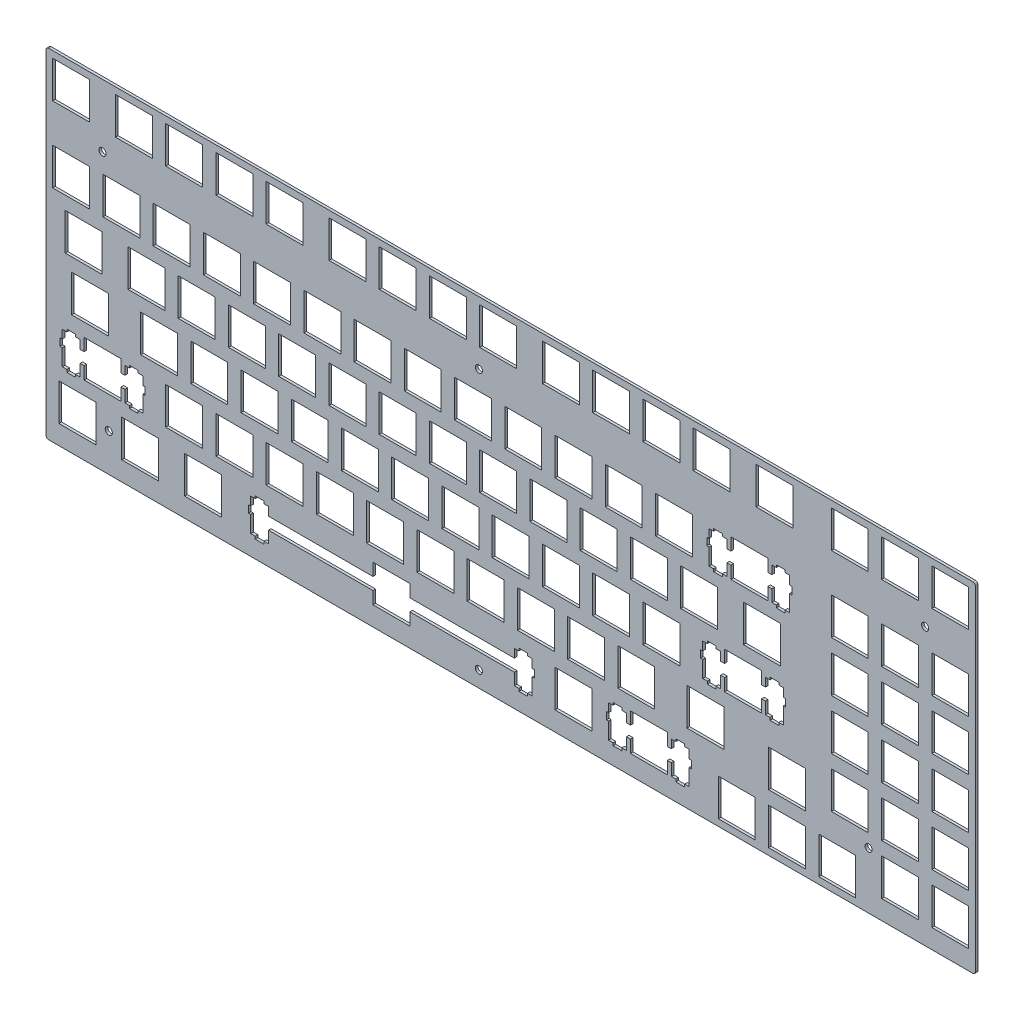
from build123d import *

# Parameters (mm, degrees)
MODEL_W             = 352.4249154
MODEL_H             = 128.586918
MODEL_W_2           = 14
MODEL_H_2           = 13.99947
MODEL_W_3           = 13.99949
MODEL_H_3           = 13.99948
MODEL_W_4           = 14.0008
MODEL_W_5           = 13.9993
MODEL_W_6           = 13.999
MODEL_H_4           = 13.9994
MODEL_W_7           = 14.00087
MODEL_H_5           = 13.9992
MODEL_W_8           = 13.9998
MODEL_W_9           = 13.99954
MODEL_W_10          = 13.99955
MODEL_W_11          = 14.0007
MODEL_W_12          = 14.001
MODEL_H_6           = 13.999
EXTRUDE_1_DEPTH     = 1
FILLET_1_R          = 1
SKETCH_2_R          = 1.35
CUT_EXTRUDE_1_DEPTH = 1.5


with BuildPart() as part:
    # Model → 凸台-拉伸1 (new body)
    with BuildSketch(Plane.XY):
        with Locations((176.3075423, 64.727541)):
            Rectangle(MODEL_W, MODEL_H)
        with Locations((262.032, 9.959765)):
            Rectangle(MODEL_W_2, MODEL_H_2, mode=Mode.SUBTRACT)
        with Locations((281.082, 9.959765)):
            Rectangle(MODEL_W_2, MODEL_H_2, mode=Mode.SUBTRACT)
        with Locations((300.132, 9.959765)):
            Rectangle(MODEL_W_2, MODEL_H_2, mode=Mode.SUBTRACT)
        Polygon((124.062, 21.722), (124.062, 17.0215), (84.4381, 17.0215), (84.4381, 20.2517), (82.7126, 20.2517), (82.7126, 21.1722), (79.412, 21.1722), (79.412, 20.2517), (77.687, 20.2517), (77.687, 17.0215), (76.8629, 17.0215), (76.8629, 14.2227), (77.687, 14.2227), (77.687, 7.95267), (79.412, 7.95267), (79.412, 6.97149), (82.7126, 6.97149), (82.7126, 7.95267), (84.4381, 7.95267), (84.4381, 12.4216), (124.062, 12.4216), (124.062, 7.72252), (138.063, 7.72252), (138.063, 12.4216), (177.687, 12.4216), (177.687, 7.95267), (179.412, 7.95267), (179.412, 6.97149), (182.713, 6.97149), (182.713, 7.95267), (184.438, 7.95267), (184.438, 14.2227), (185.262, 14.2227), (185.262, 17.0215), (184.438, 17.0215), (184.438, 20.2517), (182.713, 20.2517), (182.713, 21.1722), (179.412, 21.1722), (179.412, 20.2517), (177.687, 20.2517), (177.687, 17.0215), (138.063, 17.0215), (138.063, 21.722), align=None, mode=Mode.SUBTRACT)
        Polygon((221.695, 21.722), (221.695, 17.0215), (220.169, 17.0215), (220.169, 20.2517), (218.444, 20.2517), (218.444, 21.1722), (215.145, 21.1722), (215.145, 20.2517), (213.42, 20.2517), (213.42, 17.0215), (212.594, 17.0215), (212.594, 14.2227), (213.42, 14.2227), (213.42, 7.95267), (215.145, 7.95267), (215.145, 6.97149), (218.444, 6.97149), (218.444, 7.95267), (220.169, 7.95267), (220.169, 12.4216), (221.695, 12.4216), (221.695, 7.72252), (235.694, 7.72252), (235.694, 12.4216), (237.22, 12.4216), (237.22, 7.95267), (238.945, 7.95267), (238.945, 6.97149), (242.244, 6.97149), (242.244, 7.95267), (243.969, 7.95267), (243.969, 14.2227), (244.795, 14.2227), (244.795, 17.0215), (243.969, 17.0215), (243.969, 20.2517), (242.244, 20.2517), (242.244, 21.1722), (238.945, 21.1722), (238.945, 20.2517), (237.22, 20.2517), (237.22, 17.0215), (235.694, 17.0215), (235.694, 21.722), align=None, mode=Mode.SUBTRACT)
        with Locations((12.000655, 14.72226)):
            Rectangle(MODEL_W_3, MODEL_H_3, mode=Mode.SUBTRACT)
        with Locations((35.8124, 14.72226)):
            Rectangle(MODEL_W_4, MODEL_H_3, mode=Mode.SUBTRACT)
        with Locations((59.62565, 14.72226)):
            Rectangle(MODEL_W_5, MODEL_H_3, mode=Mode.SUBTRACT)
        with Locations((200.1195, 14.72226)):
            Rectangle(MODEL_W_6, MODEL_H_3, mode=Mode.SUBTRACT)
        with Locations((323.9445, 14.72226)):
            Rectangle(MODEL_W_6, MODEL_H_3, mode=Mode.SUBTRACT)
        with Locations((342.9945, 14.72226)):
            Rectangle(MODEL_W_6, MODEL_H_3, mode=Mode.SUBTRACT)
        with Locations((281.082, 29.0097)):
            Rectangle(MODEL_W_2, MODEL_H_4, mode=Mode.SUBTRACT)
        Polygon((14.5259, 40.7719), (14.5259, 36.0715), (13.0004, 36.0715), (13.0004, 39.3016), (11.2751, 39.3016), (11.2751, 40.2223), (7.97609, 40.2223), (7.97609, 39.3016), (6.2508, 39.3016), (6.2508, 36.0715), (5.42533, 36.0715), (5.42533, 33.2727), (6.2508, 33.2727), (6.2508, 27.0027), (7.97609, 27.0027), (7.97609, 26.0215), (11.2751, 26.0215), (11.2751, 27.0027), (13.0004, 27.0027), (13.0004, 31.4716), (14.5259, 31.4716), (14.5259, 26.7725), (28.5254, 26.7725), (28.5254, 31.4716), (30.0509, 31.4716), (30.0509, 27.0027), (31.7748, 27.0027), (31.7748, 26.0215), (35.0752, 26.0215), (35.0752, 27.0027), (36.8004, 27.0027), (36.8004, 33.2727), (37.6259, 33.2727), (37.6259, 36.0715), (36.8004, 36.0715), (36.8004, 39.3016), (35.0752, 39.3016), (35.0752, 40.2223), (31.7748, 40.2223), (31.7748, 39.3016), (30.0509, 39.3016), (30.0509, 36.0715), (28.5254, 36.0715), (28.5254, 40.7719), align=None, mode=Mode.SUBTRACT)
        with Locations((52.48185, 33.7722)):
            Rectangle(MODEL_W_5, MODEL_H_4, mode=Mode.SUBTRACT)
        with Locations((71.53185, 33.7722)):
            Rectangle(MODEL_W_5, MODEL_H_4, mode=Mode.SUBTRACT)
        with Locations((90.58185, 33.7722)):
            Rectangle(MODEL_W_5, MODEL_H_4, mode=Mode.SUBTRACT)
        with Locations((109.632, 33.7722)):
            Rectangle(MODEL_W_2, MODEL_H_4, mode=Mode.SUBTRACT)
        with Locations((128.682, 33.7722)):
            Rectangle(MODEL_W_2, MODEL_H_4, mode=Mode.SUBTRACT)
        with Locations((147.732, 33.7722)):
            Rectangle(MODEL_W_2, MODEL_H_4, mode=Mode.SUBTRACT)
        with Locations((166.782, 33.7722)):
            Rectangle(MODEL_W_2, MODEL_H_4, mode=Mode.SUBTRACT)
        with Locations((185.832, 33.7722)):
            Rectangle(MODEL_W_2, MODEL_H_4, mode=Mode.SUBTRACT)
        with Locations((204.882, 33.7722)):
            Rectangle(MODEL_W_2, MODEL_H_4, mode=Mode.SUBTRACT)
        with Locations((223.932, 33.7722)):
            Rectangle(MODEL_W_2, MODEL_H_4, mode=Mode.SUBTRACT)
        with Locations((250.1255, 33.7722)):
            Rectangle(MODEL_W_6, MODEL_H_4, mode=Mode.SUBTRACT)
        with Locations((304.8945, 33.7722)):
            Rectangle(MODEL_W_6, MODEL_H_4, mode=Mode.SUBTRACT)
        with Locations((323.9445, 33.7722)):
            Rectangle(MODEL_W_6, MODEL_H_4, mode=Mode.SUBTRACT)
        with Locations((342.9945, 33.7722)):
            Rectangle(MODEL_W_6, MODEL_H_4, mode=Mode.SUBTRACT)
        Polygon((257.412, 59.8219), (257.412, 55.1215), (255.888, 55.1215), (255.888, 58.3516), (254.161, 58.3516), (254.161, 59.2723), (250.862, 59.2723), (250.862, 58.3516), (249.137, 58.3516), (249.137, 55.1215), (248.313, 55.1215), (248.313, 52.3226), (249.137, 52.3226), (249.137, 46.0527), (250.862, 46.0527), (250.862, 45.0716), (254.161, 45.0716), (254.161, 46.0527), (255.888, 46.0527), (255.888, 50.5217), (257.412, 50.5217), (257.412, 45.8227), (271.413, 45.8227), (271.413, 50.5217), (272.937, 50.5217), (272.937, 46.0527), (274.662, 46.0527), (274.662, 45.0716), (277.963, 45.0716), (277.963, 46.0527), (279.688, 46.0527), (279.688, 52.3226), (280.512, 52.3226), (280.512, 55.1215), (279.688, 55.1215), (279.688, 58.3516), (277.963, 58.3516), (277.963, 59.2723), (274.662, 59.2723), (274.662, 58.3516), (272.937, 58.3516), (272.937, 55.1215), (271.413, 55.1215), (271.413, 59.8219), align=None, mode=Mode.SUBTRACT)
        with Locations((16.762465, 52.8223)):
            Rectangle(MODEL_W_7, MODEL_H_5, mode=Mode.SUBTRACT)
        with Locations((42.95685, 52.8223)):
            Rectangle(MODEL_W_5, MODEL_H_5, mode=Mode.SUBTRACT)
        with Locations((62.00685, 52.8223)):
            Rectangle(MODEL_W_5, MODEL_H_5, mode=Mode.SUBTRACT)
        with Locations((81.05685, 52.8223)):
            Rectangle(MODEL_W_5, MODEL_H_5, mode=Mode.SUBTRACT)
        with Locations((100.1071, 52.8223)):
            Rectangle(MODEL_W_8, MODEL_H_5, mode=Mode.SUBTRACT)
        with Locations((119.157, 52.8223)):
            Rectangle(MODEL_W_2, MODEL_H_5, mode=Mode.SUBTRACT)
        with Locations((138.207, 52.8223)):
            Rectangle(MODEL_W_2, MODEL_H_5, mode=Mode.SUBTRACT)
        with Locations((157.257, 52.8223)):
            Rectangle(MODEL_W_2, MODEL_H_5, mode=Mode.SUBTRACT)
        with Locations((176.307, 52.8223)):
            Rectangle(MODEL_W_2, MODEL_H_5, mode=Mode.SUBTRACT)
        with Locations((195.357, 52.8223)):
            Rectangle(MODEL_W_2, MODEL_H_5, mode=Mode.SUBTRACT)
        with Locations((214.407, 52.8223)):
            Rectangle(MODEL_W_2, MODEL_H_5, mode=Mode.SUBTRACT)
        with Locations((233.457, 52.8223)):
            Rectangle(MODEL_W_2, MODEL_H_5, mode=Mode.SUBTRACT)
        with Locations((304.8945, 52.8223)):
            Rectangle(MODEL_W_6, MODEL_H_5, mode=Mode.SUBTRACT)
        with Locations((323.9445, 52.8223)):
            Rectangle(MODEL_W_6, MODEL_H_5, mode=Mode.SUBTRACT)
        with Locations((342.9945, 52.8223)):
            Rectangle(MODEL_W_6, MODEL_H_5, mode=Mode.SUBTRACT)
        with Locations((14.38193, 71.8723)):
            Rectangle(MODEL_W_9, MODEL_H_5, mode=Mode.SUBTRACT)
        with Locations((38.19435, 71.8723)):
            Rectangle(MODEL_W_5, MODEL_H_5, mode=Mode.SUBTRACT)
        with Locations((57.24435, 71.8723)):
            Rectangle(MODEL_W_5, MODEL_H_5, mode=Mode.SUBTRACT)
        with Locations((76.29435, 71.8723)):
            Rectangle(MODEL_W_5, MODEL_H_5, mode=Mode.SUBTRACT)
        with Locations((95.34435, 71.8723)):
            Rectangle(MODEL_W_5, MODEL_H_5, mode=Mode.SUBTRACT)
        with Locations((114.3945, 71.8723)):
            Rectangle(MODEL_W_6, MODEL_H_5, mode=Mode.SUBTRACT)
        with Locations((133.4445, 71.8723)):
            Rectangle(MODEL_W_6, MODEL_H_5, mode=Mode.SUBTRACT)
        with Locations((152.4945, 71.8723)):
            Rectangle(MODEL_W_6, MODEL_H_5, mode=Mode.SUBTRACT)
        with Locations((171.5445, 71.8723)):
            Rectangle(MODEL_W_6, MODEL_H_5, mode=Mode.SUBTRACT)
        with Locations((190.5945, 71.8723)):
            Rectangle(MODEL_W_6, MODEL_H_5, mode=Mode.SUBTRACT)
        with Locations((209.6445, 71.8723)):
            Rectangle(MODEL_W_6, MODEL_H_5, mode=Mode.SUBTRACT)
        with Locations((228.6945, 71.8723)):
            Rectangle(MODEL_W_6, MODEL_H_5, mode=Mode.SUBTRACT)
        with Locations((247.7445, 71.8723)):
            Rectangle(MODEL_W_6, MODEL_H_5, mode=Mode.SUBTRACT)
        with Locations((271.557, 71.8723)):
            Rectangle(MODEL_W_2, MODEL_H_5, mode=Mode.SUBTRACT)
        with Locations((304.8945, 71.8723)):
            Rectangle(MODEL_W_6, MODEL_H_5, mode=Mode.SUBTRACT)
        with Locations((323.9445, 71.8723)):
            Rectangle(MODEL_W_6, MODEL_H_5, mode=Mode.SUBTRACT)
        with Locations((342.9945, 71.8723)):
            Rectangle(MODEL_W_6, MODEL_H_5, mode=Mode.SUBTRACT)
        Polygon((259.795, 97.9219), (259.795, 93.2215), (258.269, 93.2215), (258.269, 96.4516), (256.544, 96.4516), (256.544, 97.3723), (253.243, 97.3723), (253.243, 96.4516), (251.52, 96.4516), (251.52, 93.2215), (250.694, 93.2215), (250.694, 90.4226), (251.52, 90.4226), (251.52, 84.1527), (253.243, 84.1527), (253.243, 83.1716), (256.544, 83.1716), (256.544, 84.1527), (258.269, 84.1527), (258.269, 88.6217), (259.795, 88.6217), (259.795, 83.9227), (273.794, 83.9227), (273.794, 88.6217), (275.32, 88.6217), (275.32, 84.1527), (277.045, 84.1527), (277.045, 83.1716), (280.344, 83.1716), (280.344, 84.1527), (282.069, 84.1527), (282.069, 90.4226), (282.895, 90.4226), (282.895, 93.2215), (282.069, 93.2215), (282.069, 96.4516), (280.344, 96.4516), (280.344, 97.3723), (277.045, 97.3723), (277.045, 96.4516), (275.32, 96.4516), (275.32, 93.2215), (273.794, 93.2215), (273.794, 97.9219), align=None, mode=Mode.SUBTRACT)
        with Locations((9.619425, 90.9223)):
            Rectangle(MODEL_W_10, MODEL_H_5, mode=Mode.SUBTRACT)
        with Locations((28.66935, 90.9223)):
            Rectangle(MODEL_W_5, MODEL_H_5, mode=Mode.SUBTRACT)
        with Locations((47.71935, 90.9223)):
            Rectangle(MODEL_W_5, MODEL_H_5, mode=Mode.SUBTRACT)
        with Locations((66.76935, 90.9223)):
            Rectangle(MODEL_W_5, MODEL_H_5, mode=Mode.SUBTRACT)
        with Locations((85.81935, 90.9223)):
            Rectangle(MODEL_W_5, MODEL_H_5, mode=Mode.SUBTRACT)
        with Locations((104.86865, 90.9223)):
            Rectangle(MODEL_W_11, MODEL_H_5, mode=Mode.SUBTRACT)
        with Locations((123.9185, 90.9223)):
            Rectangle(MODEL_W_12, MODEL_H_5, mode=Mode.SUBTRACT)
        with Locations((142.9695, 90.9223)):
            Rectangle(MODEL_W_6, MODEL_H_5, mode=Mode.SUBTRACT)
        with Locations((162.0195, 90.9223)):
            Rectangle(MODEL_W_6, MODEL_H_5, mode=Mode.SUBTRACT)
        with Locations((181.0695, 90.9223)):
            Rectangle(MODEL_W_6, MODEL_H_5, mode=Mode.SUBTRACT)
        with Locations((200.1195, 90.9223)):
            Rectangle(MODEL_W_6, MODEL_H_5, mode=Mode.SUBTRACT)
        with Locations((219.1695, 90.9223)):
            Rectangle(MODEL_W_6, MODEL_H_5, mode=Mode.SUBTRACT)
        with Locations((238.2195, 90.9223)):
            Rectangle(MODEL_W_6, MODEL_H_5, mode=Mode.SUBTRACT)
        with Locations((304.8945, 90.9223)):
            Rectangle(MODEL_W_6, MODEL_H_5, mode=Mode.SUBTRACT)
        with Locations((323.9445, 90.9223)):
            Rectangle(MODEL_W_6, MODEL_H_5, mode=Mode.SUBTRACT)
        with Locations((342.9945, 90.9223)):
            Rectangle(MODEL_W_6, MODEL_H_5, mode=Mode.SUBTRACT)
        with Locations((9.619425, 119.4975)):
            Rectangle(MODEL_W_10, MODEL_H_6, mode=Mode.SUBTRACT)
        with Locations((33.43185, 119.4975)):
            Rectangle(MODEL_W_5, MODEL_H_6, mode=Mode.SUBTRACT)
        with Locations((52.48185, 119.4975)):
            Rectangle(MODEL_W_5, MODEL_H_6, mode=Mode.SUBTRACT)
        with Locations((71.53185, 119.4975)):
            Rectangle(MODEL_W_5, MODEL_H_6, mode=Mode.SUBTRACT)
        with Locations((90.58185, 119.4975)):
            Rectangle(MODEL_W_5, MODEL_H_6, mode=Mode.SUBTRACT)
        with Locations((114.3945, 119.4975)):
            Rectangle(MODEL_W_6, MODEL_H_6, mode=Mode.SUBTRACT)
        with Locations((133.4445, 119.4975)):
            Rectangle(MODEL_W_6, MODEL_H_6, mode=Mode.SUBTRACT)
        with Locations((152.4945, 119.4975)):
            Rectangle(MODEL_W_6, MODEL_H_6, mode=Mode.SUBTRACT)
        with Locations((171.5445, 119.4975)):
            Rectangle(MODEL_W_6, MODEL_H_6, mode=Mode.SUBTRACT)
        with Locations((195.357, 119.4975)):
            Rectangle(MODEL_W_2, MODEL_H_6, mode=Mode.SUBTRACT)
        with Locations((214.407, 119.4975)):
            Rectangle(MODEL_W_2, MODEL_H_6, mode=Mode.SUBTRACT)
        with Locations((233.457, 119.4975)):
            Rectangle(MODEL_W_2, MODEL_H_6, mode=Mode.SUBTRACT)
        with Locations((252.507, 119.4975)):
            Rectangle(MODEL_W_2, MODEL_H_6, mode=Mode.SUBTRACT)
        with Locations((276.3195, 119.4975)):
            Rectangle(MODEL_W_6, MODEL_H_6, mode=Mode.SUBTRACT)
        with Locations((304.8945, 119.4975)):
            Rectangle(MODEL_W_6, MODEL_H_6, mode=Mode.SUBTRACT)
        with Locations((323.9445, 119.4975)):
            Rectangle(MODEL_W_6, MODEL_H_6, mode=Mode.SUBTRACT)
        with Locations((342.9945, 119.4975)):
            Rectangle(MODEL_W_6, MODEL_H_6, mode=Mode.SUBTRACT)
    extrude(amount=EXTRUDE_1_DEPTH)

    # 圆角1
    fillet_1_edges = [part.edges().sort_by_distance(p)[0] for p in [
        (0.0950846, 129.021, 0.5),
        (352.52, 129.021, 0.5),
        (352.52, 0.434082, 0.5),
        (0.0950846, 0.434082, 0.5),
    ]]
    fillet(fillet_1_edges, radius=FILLET_1_R)

    # 草图2 → 切除-拉伸1 (cut)
    with BuildSketch(Plane.XY.offset(1)):
        with Locations((21.5257, 105.20995)):
            Circle(SKETCH_2_R)
        with Locations((23.9062, 14.72226)):
            Circle(SKETCH_2_R)
        with Locations((164.2565, 105.20995)):
            Circle(SKETCH_2_R)
        with Locations((312.0385, 21.866)):
            Circle(SKETCH_2_R)
        with Locations((333.4695, 105.20995)):
            Circle(SKETCH_2_R)
        with Locations((164.2565, 6.434082)):
            Circle(SKETCH_2_R)
    extrude(amount=-CUT_EXTRUDE_1_DEPTH, mode=Mode.SUBTRACT)


solid = part.part
